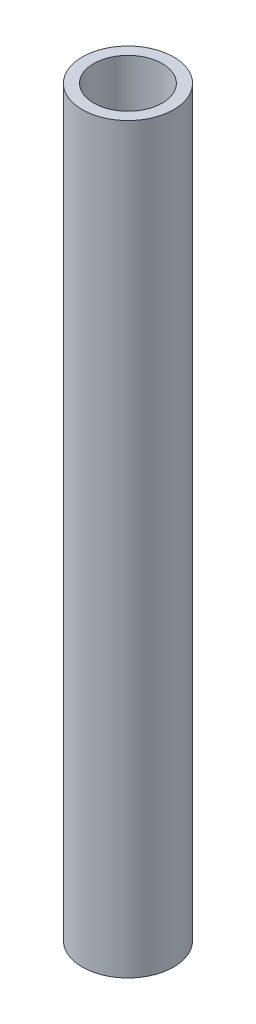
from build123d import *

# Parameters (mm, degrees)
SKETCH_1_R      = 8
SKETCH_1_R_2    = 6
EXTRUDE_1_DEPTH = 130


with BuildPart() as part:
    # 草图1 → 凸台-拉伸1 (new body)
    with BuildSketch(Plane(origin=(0, 0, 0), x_dir=(1, 0, 0), z_dir=(0, 1, 0))):
        Circle(SKETCH_1_R)
        Circle(SKETCH_1_R_2, mode=Mode.SUBTRACT)
    extrude(amount=EXTRUDE_1_DEPTH)


solid = part.part
